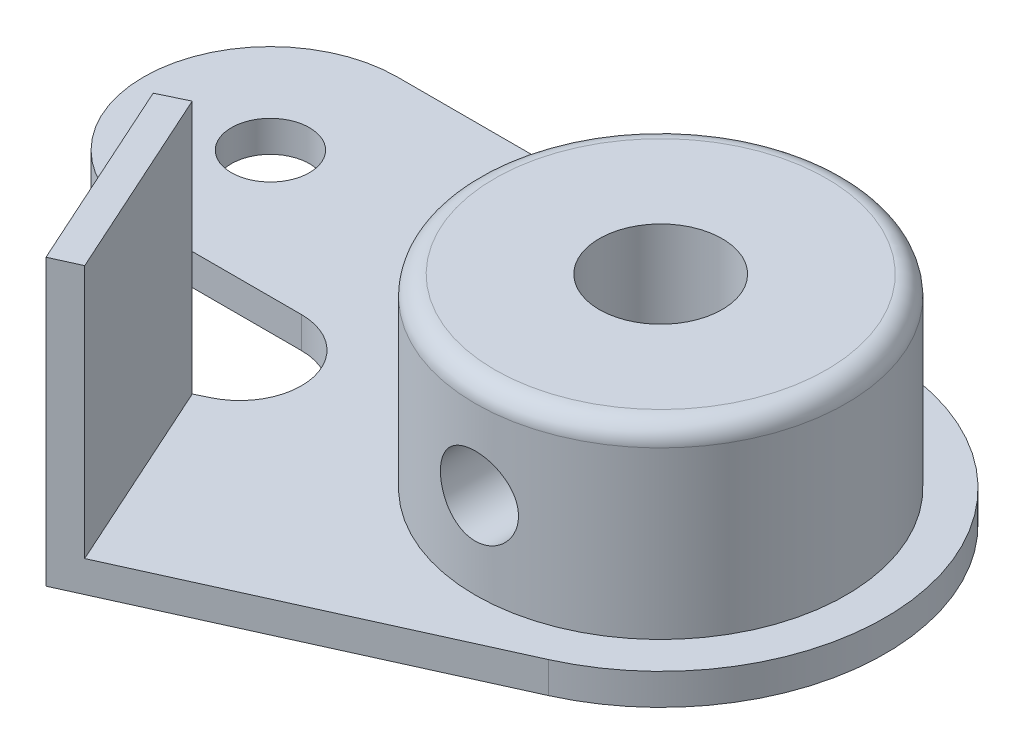
from build123d import *

# Parameters (mm, degrees)
ESQUISSE1_R             = 3.15
ESQUISSE1_R_2           = 2
BOSS_EXTRU_1_DEPTH      = 1.6
ESQUISSE2_R             = 9.5
ESQUISSE2_R_2           = 3.15
BOSS_EXTRU_2_DEPTH      = 9.5
CONG_1_R                = 1
BOSS_EXTRU_3_DEPTH      = 13
ESQUISSE4_R             = 2
ENL_V_MAT_EXTRU_1_DEPTH = 19.5


with BuildPart() as part:
    # Esquisse1 → Boss.-Extru.1 (new body)
    with BuildSketch(Plane(origin=(0, 0, 0), x_dir=(1, 0, 0), z_dir=(0, 1, 0))):
        with BuildLine():
            Line((0, 11.5), (-25, 11.5))
            ThreePointArc((-25, 11.5), (-31.5, 5), (-25, -1.5))
            Line((-25, -1.5), (-16.90921754, -1.5))
            ThreePointArc((-16.90921754, -1.5), (-13.826301978, -3.956560509), (-15.532463951, -7.510159982))
            Line((-15.532463951, -7.510159982), (-17.532463951, -8.477187494))
            Line((-17.532463951, -8.477187494), (-13, -18.5))
            Line((-13, -18.5), (4.73848504, -10.478394893))
            ThreePointArc((4.73848504, -10.478394893), (11.241697854, 2.423680954), (0, 11.5))
        make_face()
        Circle(ESQUISSE1_R, mode=Mode.SUBTRACT)
        with Locations((-25, 5)):
            Circle(ESQUISSE1_R_2, mode=Mode.SUBTRACT)
    extrude(amount=BOSS_EXTRU_1_DEPTH)

    # Esquisse2 → Boss.-Extru.2 (add)
    with BuildSketch(Plane(origin=(0, 1.6, 0), x_dir=(1, 0, 0), z_dir=(0, 1, 0))):
        Circle(ESQUISSE2_R)
        Circle(ESQUISSE2_R_2, mode=Mode.SUBTRACT)
    extrude(amount=BOSS_EXTRU_2_DEPTH)

    # Congé1
    cong_1_edges = [part.edges().sort_by_distance(p)[0] for p in [
        (-9.5, 11.1, 0),
    ]]
    fillet(cong_1_edges, radius=CONG_1_R)

    # Esquisse3 → Boss.-Extru.3 (add)
    with BuildSketch(Plane(origin=(0, 1.6, 0), x_dir=(1, 0, 0), z_dir=(0, 1, 0))):
        Polygon((-17.532463951, -8.477187494), (-13, -18.5), (-11.633703391, -17.88214048), (-16.182035998, -7.824237002), align=None)
    extrude(amount=BOSS_EXTRU_3_DEPTH)

    # Esquisse4 → Enlèv. mat.-Extru.1 (cut, through all)
    with BuildSketch(Plane.XY):
        with Locations((0, 6)):
            Circle(ESQUISSE4_R)
    extrude(amount=ENL_V_MAT_EXTRU_1_DEPTH, mode=Mode.SUBTRACT)


solid = part.part
